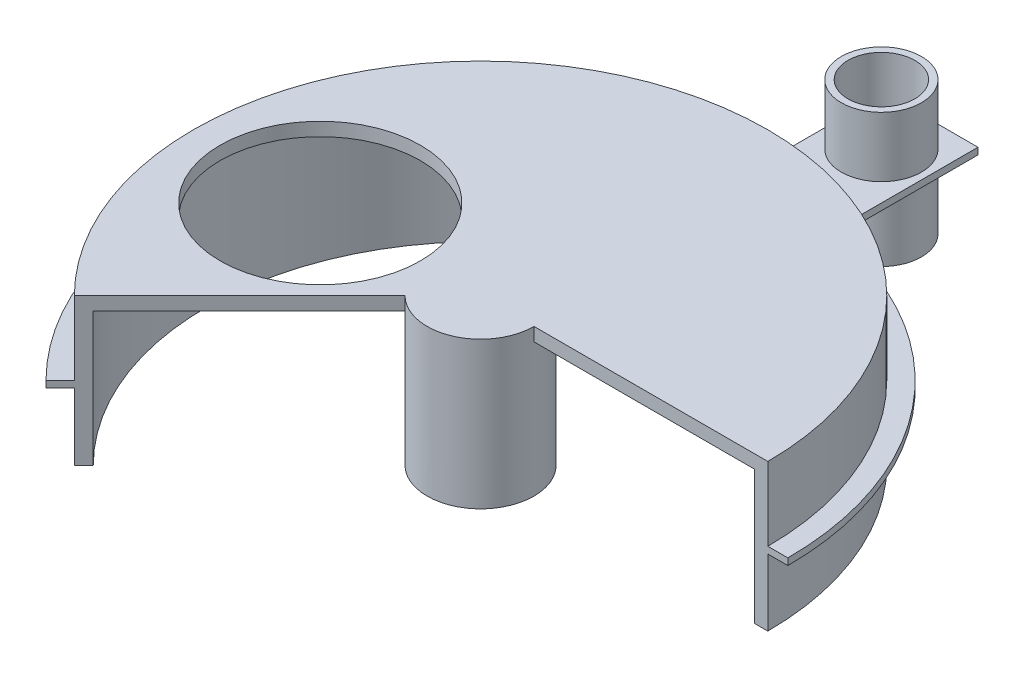
from build123d import *
from build123d.topology import SkipClean

# Parameters (mm, degrees)
CROQUIS1_R                = 40
CROQUIS1_R_2              = 35
SALIENTE_EXTRUIR1_DEPTH   = 100
CROQUIS2_R                = 30
CROQUIS2_R_2              = 25
SALIENTE_EXTRUIR2_DEPTH   = 100
SALIENTE_EXTRUIR2_2_DEPTH = 100
CROQUIS3_R                = 75
SALIENTE_EXTRUIR3_DEPTH   = 10
SALIENTE_EXTRUIR9_DEPTH   = 5
SALIENTE_EXTRUIR11_DEPTH  = 10


with BuildPart() as part:
    # Croquis1 → Saliente-Extruir1 (new body)
    with BuildSketch(Plane(origin=(0, 0, 0), x_dir=(1, 0, 0), z_dir=(0, 1, 0))):
        Circle(CROQUIS1_R)
        Circle(CROQUIS1_R_2, mode=Mode.SUBTRACT)
    extrude(amount=SALIENTE_EXTRUIR1_DEPTH)



with BuildPart() as body_2:
    # Croquis2 → Saliente-Extruir2 (new body)
    with BuildSketch(Plane(origin=(0, 0, 0), x_dir=(1, 0, 0), z_dir=(0, 1, 0))):
        with Locations((0, 300)):
            Circle(CROQUIS2_R)
        with Locations((0, 300)):
            Circle(CROQUIS2_R_2, mode=Mode.SUBTRACT)
    extrude(amount=SALIENTE_EXTRUIR2_DEPTH)


with BuildPart() as body_3:
    # Croquis2 → Saliente-Extruir2 2 (new body)
    with BuildSketch(Plane(origin=(0, 0, 0), x_dir=(1, 0, 0), z_dir=(0, 1, 0))):
        with BuildLine():
            Line((215, 0), (205, 0))
            ThreePointArc((205, 0), (0, 205), (-205, 0))
            ThreePointArc((-205, 0), (-189.395304, -78.450104), (-144.95689, -144.95689))
            Line((-144.95689, -144.95689), (-152.027958, -152.027958))
            ThreePointArc((-152.027958, -152.027958), (-198.634099, -82.276938), (-215, 0))
            ThreePointArc((-215, 0), (0, 215), (215, 0))
        make_face()
    extrude(amount=SALIENTE_EXTRUIR2_2_DEPTH)


with BuildPart() as part_1:
    add(part.part)

    add(body_3.part)  # Saliente-Extruir3 merges body 3
    # Croquis3 → Saliente-Extruir3 (add)
    with BuildSketch(Plane(origin=(0, 100, 0), x_dir=(1, 0, 0), z_dir=(0, 1, 0))):
        with BuildLine():
            ThreePointArc((215, 0), (-82.276938, 198.634099), (-152.027958, -152.027958))
            Line((-152.027958, -152.027958), (0, 0))
            Line((0, 0), (215, 0))
        make_face()
        with Locations((-120, 0)):
            Circle(CROQUIS3_R, mode=Mode.SUBTRACT)
    extrude(amount=SALIENTE_EXTRUIR3_DEPTH)

    # Croquis6 → Saliente-Extruir9 (add)
    with BuildSketch(Plane(origin=(0, 50, 0), x_dir=(1, 0, 0), z_dir=(0, 1, 0))):
        with BuildLine():
            Line((-162.63456, -162.63456), (-152.027958, -152.027958))
            ThreePointArc((-152.027958, -152.027958), (-82.276938, 198.634099), (215, 0))
            Line((215, 0), (230, 0))
            ThreePointArc((230, 0), (174.570903, 149.749791), (35, 227.321358))
            Line((35, 227.321358), (35, 337.321358))
            Line((35, 337.321358), (-35, 337.321358))
            Line((-35, 337.321358), (-35, 227.321358))
            ThreePointArc((-35, 227.321358), (-218.589248, 71.545375), (-162.63456, -162.63456))
        make_face()
    extrude(amount=SALIENTE_EXTRUIR9_DEPTH)

    # Croquis8 → Saliente-Extruir11 (add)
    with SkipClean():  # the faces are left unmerged after this step: merging them gives an invalid solid
        with BuildSketch(Plane(origin=(0, 100, 0), x_dir=(1, 0, 0), z_dir=(0, 1, 0))):
            with BuildLine():
                Line((0, 0), (-28.284271, -28.284271))
                ThreePointArc((-28.284271, -28.284271), (15.307337, -36.955181), (40, 0))
                Line((40, 0), (0, 0))
            make_face()
        extrude(amount=SALIENTE_EXTRUIR11_DEPTH)


solid = Compound([body_2.part, part_1.part])
